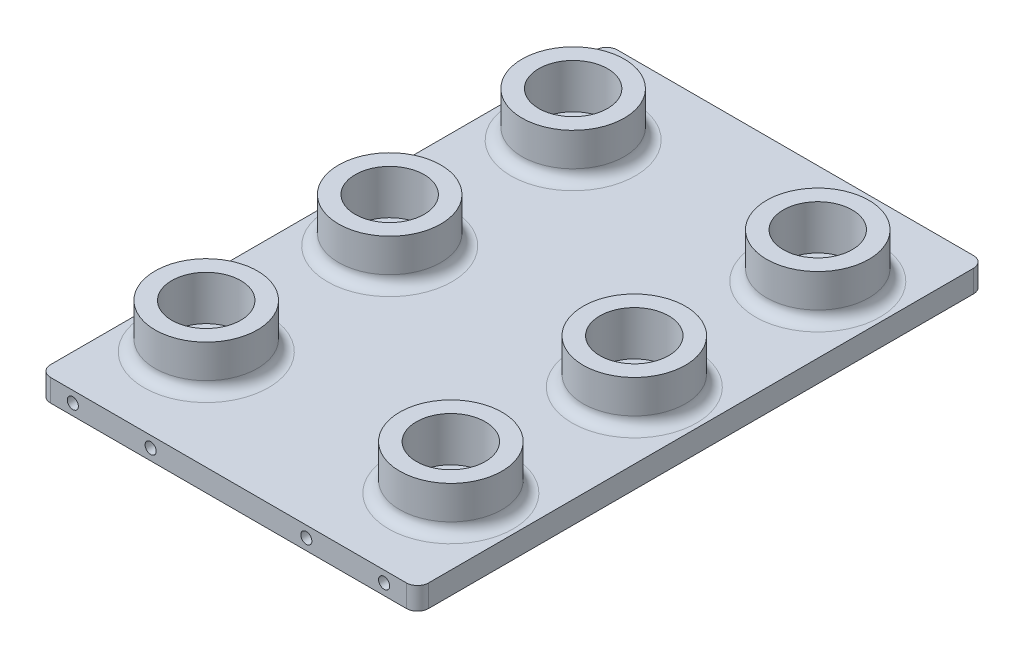
from build123d import *

# Parameters (mm, degrees)
SKETCH1_W           = 43.18
SKETCH1_H           = 64.77
BOSS_EXTRUDE1_DEPTH = 2.54
SKETCH3_R           = 0.635
CUT_EXTRUDE2_DEPTH  = 2.54
SKETCH5_R           = 5.842
SKETCH5_R_2         = 3.937
BOSS_EXTRUDE3_DEPTH = 5.08
FILLET2_R           = 1.27


with BuildPart() as part:
    # Sketch1 → Boss-Extrude1 (new body)
    with BuildSketch(Plane(origin=(0, 0, 0), x_dir=(1, 0, 0), z_dir=(0, 1, 0))):
        Rectangle(SKETCH1_W, SKETCH1_H)
    extrude(amount=BOSS_EXTRUDE1_DEPTH)

    # Sketch3 → Cut-Extrude2 (cut)
    with BuildSketch(Plane.XY.offset(32.385)):
        with Locations((-17.78, 1.27)):
            Circle(SKETCH3_R)
        with Locations((-8.89, 1.27)):
            Circle(SKETCH3_R)
        with Locations((8.89, 1.27)):
            Circle(SKETCH3_R)
        with Locations((17.78, 1.27)):
            Circle(SKETCH3_R)
    cut_extrude2 = extrude(amount=-CUT_EXTRUDE2_DEPTH, mode=Mode.SUBTRACT)

    # Mirror1: Cut-Extrude2 across plane
    add(cut_extrude2.mirror(Plane.XY), mode=Mode.SUBTRACT)

    # Sketch5 → Boss-Extrude3 (add)
    with BuildSketch(Plane(origin=(0, 2.54, 0), x_dir=(1, 0, 0), z_dir=(0, 1, 0))):
        with Locations((13.97, 20.955)):
            Circle(SKETCH5_R)
        with Locations((13.97, 20.955)):
            Circle(SKETCH5_R_2, mode=Mode.SUBTRACT)
        with Locations((-13.97, 20.955)):
            Circle(SKETCH5_R)
        with Locations((-13.97, 20.955)):
            Circle(SKETCH5_R_2, mode=Mode.SUBTRACT)
        with Locations((13.97, -20.955)):
            Circle(SKETCH5_R)
        with Locations((13.97, -20.955)):
            Circle(SKETCH5_R_2, mode=Mode.SUBTRACT)
        with Locations((-13.97, -20.955)):
            Circle(SKETCH5_R)
        with Locations((-13.97, -20.955)):
            Circle(SKETCH5_R_2, mode=Mode.SUBTRACT)
        with Locations((-13.97, 0)):
            Circle(SKETCH5_R)
        with Locations((-13.97, 0)):
            Circle(SKETCH5_R_2, mode=Mode.SUBTRACT)
        with Locations((13.97, 0)):
            Circle(SKETCH5_R)
        with Locations((13.97, 0)):
            Circle(SKETCH5_R_2, mode=Mode.SUBTRACT)
    extrude(amount=BOSS_EXTRUDE3_DEPTH)

    # Fillet2
    fillet2_edges = [part.edges().sort_by_distance(p)[0] for p in [
        (8.128, 2.54, -20.955),
        (-19.812, 2.54, -20.955),
        (8.128, 2.54, 20.955),
        (-19.812, 2.54, 20.955),
        (-19.812, 2.54, 0),
        (8.128, 2.54, 0),
        (21.59, 1.27, 32.385),
        (-21.59, 1.27, 32.385),
        (-21.59, 1.27, -32.385),
        (21.59, 1.27, -32.385),
    ]]
    fillet(fillet2_edges, radius=FILLET2_R)


solid = part.part
